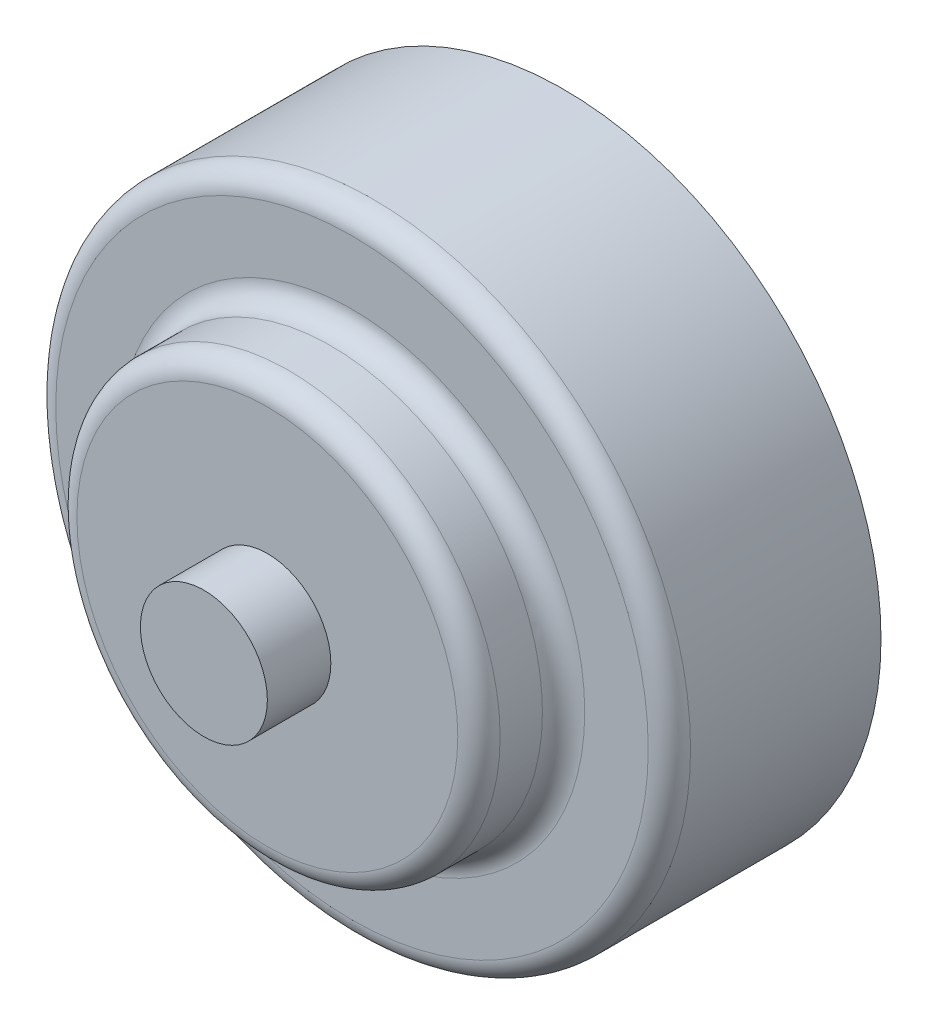
from build123d import *

# Parameters (mm, degrees)
SKETCH1_R           = 75
BOSS_EXTRUDE1_DEPTH = 50
SKETCH2_R           = 50
BOSS_EXTRUDE2_DEPTH = 20
SKETCH3_R           = 15
BOSS_EXTRUDE3_DEPTH = 15
FILLET1_R           = 5


with BuildPart() as part:
    # Sketch1 → Boss-Extrude1 (new body)
    with BuildSketch(Plane.XY):
        Circle(SKETCH1_R)
    extrude(amount=BOSS_EXTRUDE1_DEPTH)

    # Sketch2 → Boss-Extrude2 (add)
    with BuildSketch(Plane.XY.offset(50)):
        Circle(SKETCH2_R)
    extrude(amount=BOSS_EXTRUDE2_DEPTH)

    # Sketch3 → Boss-Extrude3 (add)
    with BuildSketch(Plane.XY.offset(70)):
        Circle(SKETCH3_R)
    extrude(amount=BOSS_EXTRUDE3_DEPTH)

    # Fillet1
    fillet1_edges = [part.edges().sort_by_distance(p)[0] for p in [
        (-75, 0, 50),
        (-50, 0, 50),
        (-50, 0, 70),
    ]]
    fillet(fillet1_edges, radius=FILLET1_R)


solid = part.part
